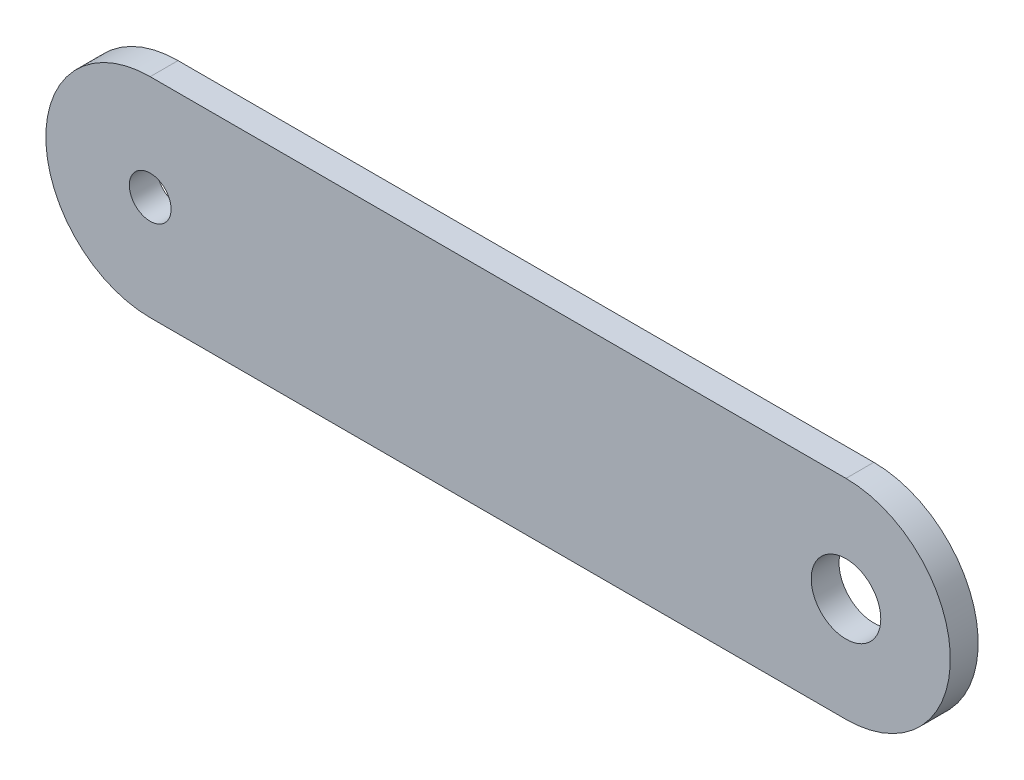
from build123d import *

# Parameters (mm, degrees)
BOSS_EXTRUDE1_DEPTH = 2
CUT_EXTRUDE1_REACH  = 4
SKETCH2_R           = 1.5
SKETCH2_R_2         = 2.5


with BuildPart() as part:
    # Sketch1 → Boss-Extrude1 (new body)
    with BuildSketch(Plane.XY):
        with BuildLine():
            Line((-25, -7.5), (25, -7.5))
            ThreePointArc((25, -7.5), (32.5, 0), (25, 7.5))
            Line((25, 7.5), (-25, 7.5))
            ThreePointArc((-25, 7.5), (-32.5, 0), (-25, -7.5))
        make_face()
    extrude(amount=-BOSS_EXTRUDE1_DEPTH)

    # Sketch2 → Cut-Extrude1 (cut, up to next)
    with BuildSketch(Plane.XY, mode=Mode.PRIVATE) as cut_extrude1_sk1:
        with Locations((-25, 0)):
            Circle(SKETCH2_R)
    cut_extrude1_tool1 = extrude(cut_extrude1_sk1.sketch, amount=-CUT_EXTRUDE1_REACH, mode=Mode.PRIVATE) & part.part
    add(cut_extrude1_tool1.solids().sort_by_distance((-25, 0, 0))[0], mode=Mode.SUBTRACT)
    # Sketch2 → Cut-Extrude1 (cut, up to next)
    with BuildSketch(Plane.XY, mode=Mode.PRIVATE) as cut_extrude1_sk2:
        with Locations((25, 0)):
            Circle(SKETCH2_R_2)
    cut_extrude1_tool2 = extrude(cut_extrude1_sk2.sketch, amount=-CUT_EXTRUDE1_REACH, mode=Mode.PRIVATE) & part.part
    add(cut_extrude1_tool2.solids().sort_by_distance((25, 0, 0))[0], mode=Mode.SUBTRACT)


solid = part.part
